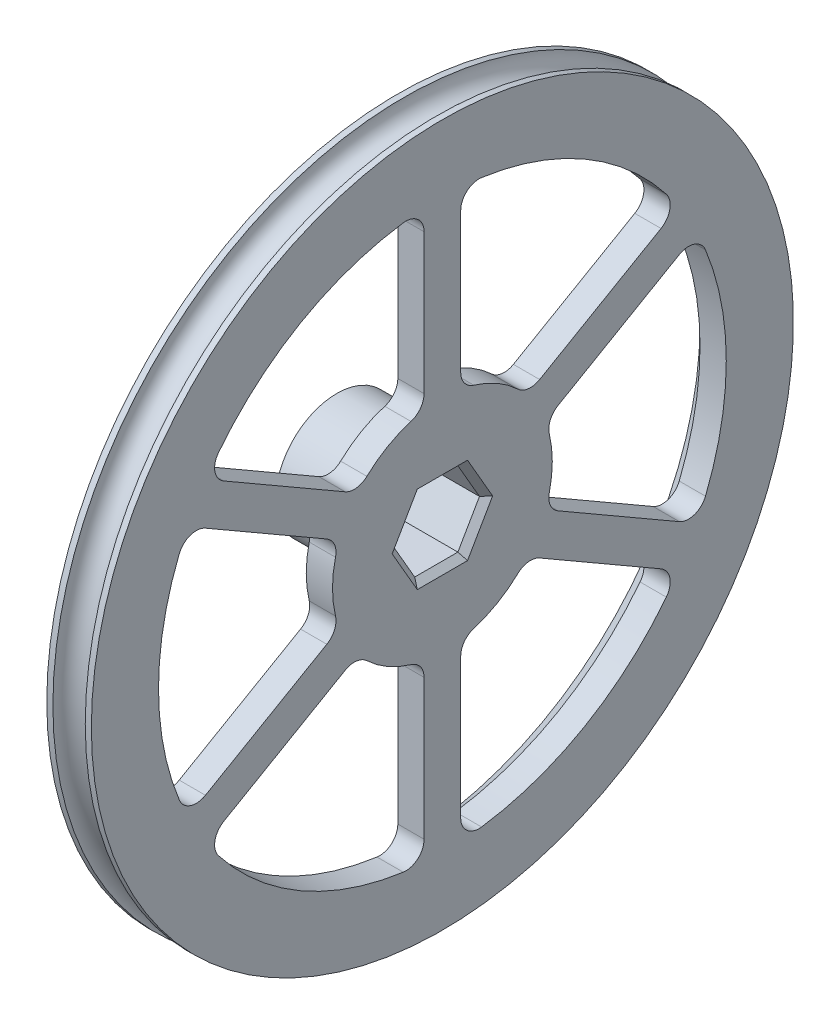
from build123d import *

# Parameters (mm, degrees)
SKETCH2_R           = 2.649999999999999
CUT_EXTRUDE1_DEPTH  = 5
SKETCH5_R           = 2
CUT_EXTRUDE2_DEPTH  = 5
BOSS_EXTRUDE1_START = 10
SKETCH6_R           = 10
SKETCH6_R_2         = 2
BOSS_EXTRUDE1_DEPTH = 10
CUT_EXTRUDE3_DEPTH  = 10
CUT_EXTRUDE4_DEPTH  = 90.00000000000003
FILLET1_R           = 3
CHAMFER1_SIZE       = 1


with BuildPart() as part:
    # Sketch1 → Revolve1 (revolve)
    with BuildSketch(Plane(origin=(0, 0, 0), x_dir=(1, 0, 0), z_dir=(0, 1, 0)), mode=Mode.PRIVATE) as revolve1_sk:
        Polygon((3.65, 0), (3.65, 57.5), (-3.65, 57.5), (-3.65, 49.5), (-0.6499999999999997, 46.5), (-0.6499999999999951, 16.5), (-0.6499999999999819, 12.999999999999988), (-3.650000000000002, 9.999999999999792), (-3.65, 0), align=None)
    revolve(revolve1_sk.sketch.rotate(Axis((-3.65, 0, 0), (1, 0, 0)), 180), axis=Axis((-3.65, 0, 0), (1, 0, 0)))

    # Sketch2 → Cut-Revolve1 (revolve, cut)
    with BuildSketch(Plane(origin=(0, 0, 0), x_dir=(1, 0, 0), z_dir=(0, 1, 0)), mode=Mode.PRIVATE) as cut_revolve1_sk:
        with Locations((0, 57.5)):
            Circle(SKETCH2_R)
    revolve(cut_revolve1_sk.sketch.rotate(Axis((-3.65, 0, 0), (1, 0, 0)), 180), axis=Axis((-3.65, 0, 0), (1, 0, 0)), mode=Mode.SUBTRACT)

    # Sketch4 → Cut-Extrude1 (cut)
    with BuildSketch(Plane(origin=(3.65, 0, 0), x_dir=(0, 0, -1), z_dir=(1, 0, 0))):
        Polygon((7.0725407975729215, 1.73e-15), (3.536270398786459, 6.125000000000007), (-3.536270398786464, 6.125000000000006), (-7.072540797572923, -8.7e-16), (-3.53627039878646, -6.125000000000006), (3.5362703987864603, -6.125000000000006), align=None)
    extrude(amount=-CUT_EXTRUDE1_DEPTH, mode=Mode.SUBTRACT)

    # Sketch5 → Cut-Extrude2 (cut)
    with BuildSketch(Plane.ZY.offset(3.6500000000000012)):
        Circle(SKETCH5_R)
    extrude(amount=-CUT_EXTRUDE2_DEPTH, mode=Mode.SUBTRACT)

    # Sketch6 → Boss-Extrude1 (add)
    with BuildSketch(Plane.ZY.offset(3.6500000000000012).offset(BOSS_EXTRUDE1_START)):
        Circle(SKETCH6_R)
        Circle(SKETCH6_R_2, mode=Mode.SUBTRACT)
    extrude(amount=-BOSS_EXTRUDE1_DEPTH)

    # Sketch7 → Cut-Extrude3 (cut)
    with BuildSketch(Plane(origin=(-1.35, 0, 0), x_dir=(0, 0, -1), z_dir=(1, 0, 0))):
        Polygon((3.5362703987864603, -6.125000000000006), (7.0725407975729215, 1.73e-15), (3.536270398786459, 6.125000000000007), (-3.536270398786464, 6.125000000000006), (-7.072540797572923, -8.7e-16), (-3.53627039878646, -6.125000000000006), align=None)
    extrude(amount=-CUT_EXTRUDE3_DEPTH, mode=Mode.SUBTRACT)

    # Sketch8 → Cut-Extrude4 (cut)
    with BuildSketch(Plane.ZY.offset(0.6499999999999885)):
        with BuildLine():
            Line((14.088457268121097, 11.598076211355), (38.68628497385596, 25.79963865874104))
            ThreePointArc((38.68628497385596, 25.79963865874104), (23.24999999999963, 40.2701812759766), (2.999999999999999, 46.40312489477406))
            Line((2.999999999999999, 46.40312489477406), (3.0000000000000164, 18.00000000000186))
            Line((3.0000000000000164, 18.00000000000186), (3, 17.748239349298846))
            ThreePointArc((3, 17.748239349298846), (8.999999999999696, 15.588457268120239), (13.870426148938957, 11.4721958860035))
            Line((13.870426148938957, 11.4721958860035), (14.088457268121097, 11.598076211355))
        make_face()
        with BuildLine():
            Line((-2.9999999999999827, 18.000000000001936), (-2.999999999999999, 46.40312489477406))
            ThreePointArc((-2.999999999999999, 46.40312489477406), (-23.25000000000001, 40.27018127597639), (-38.68628497385646, 25.799638658740314))
            Line((-38.68628497385646, 25.799638658740314), (-14.08845726812106, 11.598076211354021))
            Line((-14.08845726812106, 11.598076211354021), (-13.870426148939515, 11.472195886002819))
            ThreePointArc((-13.870426148939515, 11.472195886002819), (-9.000000000000009, 15.588457268119885), (-3, 17.748239349298846))
            Line((-3, 17.748239349298846), (-2.9999999999999827, 18.000000000001936))
        make_face()
        with BuildLine():
            Line((17.088457268121093, 6.401923788647327), (41.68628497385644, 20.603486236033717))
            ThreePointArc((41.68628497385644, 20.603486236033717), (46.5, 4.2591e-13), (41.686284973856814, -20.603486236032953))
            Line((41.686284973856814, -20.603486236032953), (17.088457268121957, -6.401923788646879))
            Line((17.088457268121957, -6.401923788646879), (16.870426148939835, -6.276043463295346))
            ThreePointArc((16.870426148939835, -6.276043463295346), (18.000000000000146, 4.3265e-13), (16.870426148939533, 6.276043463296158))
            Line((16.870426148939533, 6.276043463296158), (17.088457268121093, 6.401923788647327))
        make_face()
        with BuildLine():
            Line((14.088457268121054, -11.598076211354028), (38.686284973856445, -25.799638658740335))
            ThreePointArc((38.686284973856445, -25.799638658740335), (23.25000000000037, -40.27018127597618), (3.00000000000084, -46.403124894773995))
            Line((3.00000000000084, -46.403124894773995), (3.0000000000008593, -18.000000000001883))
            Line((3.0000000000008593, -18.000000000001883), (3.000000000000877, -17.748239349298846))
            ThreePointArc((3.000000000000877, -17.748239349298846), (9.000000000000448, -15.588457268119802), (13.87042614893951, -11.472195886002828))
            Line((13.87042614893951, -11.472195886002828), (14.088457268121054, -11.598076211354028))
        make_face()
        with BuildLine():
            Line((-3.0000000000000413, -18.000000000001357), (-2.9999999999999933, -46.40312489477406))
            ThreePointArc((-2.9999999999999933, -46.40312489477406), (-23.24999999999963, -40.2701812759766), (-38.68628497385596, -25.799638658741056))
            Line((-38.68628497385596, -25.799638658741056), (-14.088457268121093, -11.598076211355007))
            Line((-14.088457268121093, -11.598076211355007), (-13.870426148938956, -11.472195886003506))
            ThreePointArc((-13.870426148938956, -11.472195886003506), (-8.999999999999696, -15.588457268120242), (-3.000000000000022, -17.748239349298988))
            Line((-3.000000000000022, -17.748239349298988), (-3.0000000000000413, -18.000000000001357))
        make_face()
        with BuildLine():
            Line((-17.088457268121093, -6.401923788647334), (-41.68628497385644, -20.603486236033735))
            ThreePointArc((-41.68628497385644, -20.603486236033735), (-46.5, -4.2796e-13), (-41.68628497385683, 20.60348623603293))
            Line((-41.68628497385683, 20.60348623603293), (-17.08845726812196, 6.40192378864687))
            Line((-17.08845726812196, 6.40192378864687), (-16.87042614893984, 6.276043463295337))
            ThreePointArc((-16.87042614893984, 6.276043463295337), (-18.000000000000146, -4.4544e-13), (-16.870426148939533, -6.276043463296166))
            Line((-16.870426148939533, -6.276043463296166), (-17.088457268121093, -6.401923788647334))
        make_face()
    extrude(amount=-CUT_EXTRUDE4_DEPTH, mode=Mode.SUBTRACT)

    # Fillet1
    fillet1_edges = [part.edges().sort_by_distance(p)[0] for p in [
        (1.5000000000000058, -11.47219588600283, 13.87042614893951),
        (1.5000000000000058, -25.799638658740335, 38.686284973856445),
        (1.5000000000000058, -46.403124894773995, 3.0000000000008398),
        (1.5000000000000058, -17.74823934929885, 3.0000000000008775),
        (1.5000000000000058, 6.276043463296158, 16.870426148939536),
        (1.5000000000000058, 20.603486236033717, 41.686284973856445),
        (1.5000000000000058, -20.603486236032957, 41.686284973856814),
        (1.5000000000000058, -6.276043463295347, 16.870426148939835),
        (1.5000000000000058, 17.748239349298842, -2.9999999999999982),
        (1.5000000000000058, 11.472195886002819, -13.870426148939515),
        (1.5000000000000058, 25.799638658740314, -38.68628497385646),
        (1.5000000000000058, 46.403124894774066, -2.999999999999999),
        (1.5000000000000058, -6.276043463296168, -16.87042614893953),
        (1.5000000000000058, -20.60348623603374, -41.686284973856445),
        (1.5000000000000058, 20.603486236032932, -41.68628497385683),
        (1.5000000000000058, 6.276043463295337, -16.870426148939835),
        (1.5000000000000058, 17.74823934929885, 3),
        (1.5000000000000058, 46.403124894774066, 3.0000000000000004),
        (1.5000000000000058, 25.799638658741042, 38.68628497385596),
        (1.5000000000000058, 11.472195886003501, 13.870426148938959),
        (1.5000000000000058, -17.748239349298988, -3.0000000000000218),
        (1.5000000000000058, -46.40312489477405, -2.999999999999994),
        (1.5000000000000058, -25.799638658741056, -38.686284973855955),
        (1.5000000000000058, -11.472195886003506, -13.870426148938956),
    ]]
    fillet(fillet1_edges, radius=FILLET1_R)

    # Chamfer1
    chamfer1_edges = [part.edges().sort_by_distance(p)[0] for p in [
        (3.65, -3.062500000000002, -5.304405598179691),
        (3.65, 3.0625000000000044, -5.30440559817969),
        (3.65, 6.125000000000007, 2.66e-15),
        (3.65, 3.0625000000000027, 5.304405598179693),
        (3.65, -3.0625000000000036, 5.304405598179692),
        (3.65, -6.125000000000006, 0),
    ]]
    chamfer(chamfer1_edges, length=CHAMFER1_SIZE)


solid = part.part
